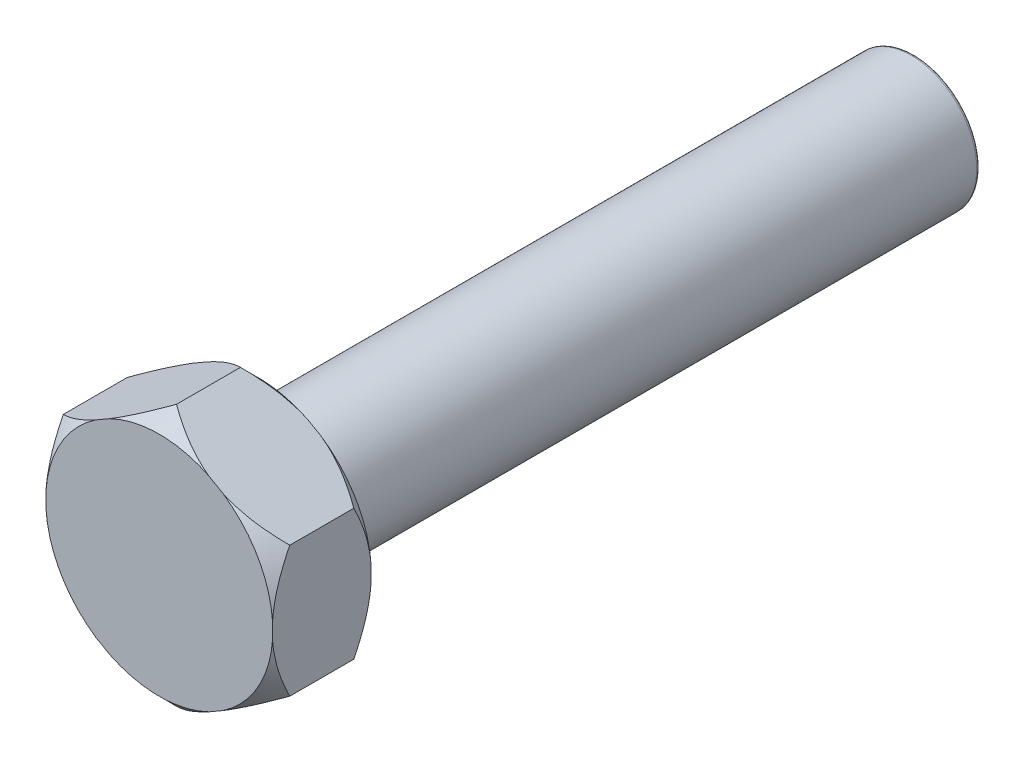
from build123d import *

# Parameters (mm, degrees)
EXTRUDE_1_DEPTH = 6
SKETCH_2_R      = 4
EXTRUDE_2_DEPTH = 40
FILLET_3_R      = 0.2


with BuildPart() as part:
    # 草图1 → 凸台-拉伸1 (new body)
    with BuildSketch(Plane.XY):
        Polygon((0, 7.967433715), (-6.9, 3.983716857), (-6.9, -3.983716857), (0, -7.967433715), (6.9, -3.983716857), (6.9, 3.983716857), align=None)
    extrude(amount=-EXTRUDE_1_DEPTH)

    # 草图2 → 凸台-拉伸2 (add)
    with BuildSketch(Plane(origin=(0, 0, -6), x_dir=(-1, 0, 0), z_dir=(0, 0, -1))):
        Circle(SKETCH_2_R)
    extrude(amount=EXTRUDE_2_DEPTH)

    # 草图3 → 切除-旋转1 (revolve, cut)
    with BuildSketch(Plane(origin=(0, 0, 0), x_dir=(0, 0, -1), z_dir=(1, 0, 0))):
        Polygon((0, -6.917433715), (1.05, -7.967433715), (0, -7.967433715), align=None)
        Polygon((6, -6.917433715), (4.95, -7.967433715), (6, -7.967433715), align=None)
    revolve(axis=Axis((0, 0, 0), (0, 0, 1)), mode=Mode.SUBTRACT)

    # 圆角3
    fillet_3_edges = [part.edges().sort_by_distance(p)[0] for p in [
        (4, 0, -46),
    ]]
    fillet(fillet_3_edges, radius=FILLET_3_R)


solid = part.part
